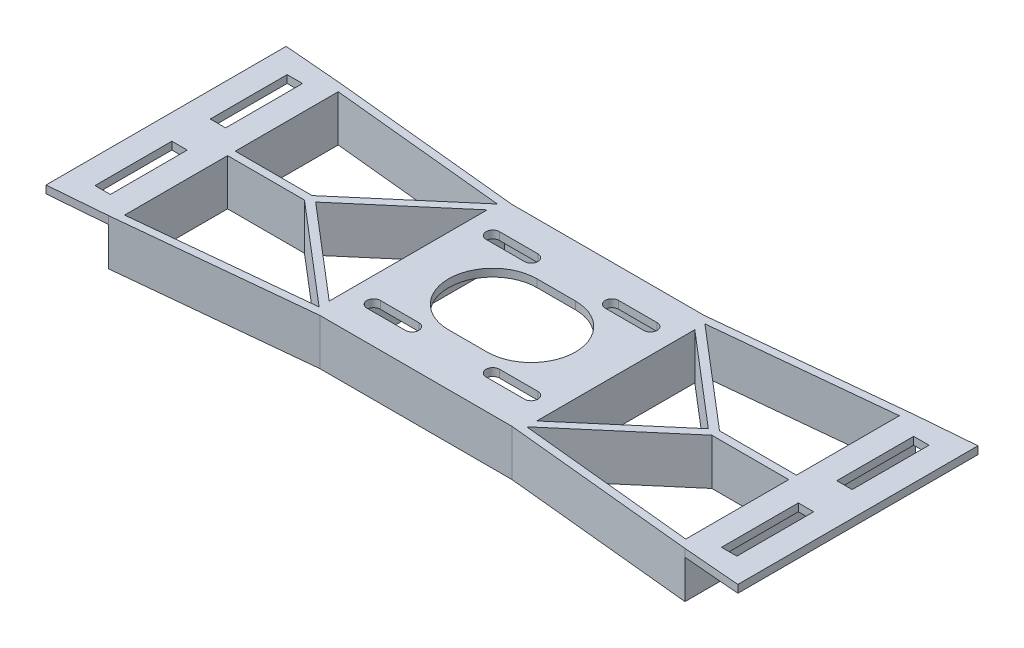
from build123d import *

# Parameters (mm, degrees)
SKETCH1_W           = 170
SKETCH1_H           = 50
BOSS_EXTRUDE1_DEPTH = 2
SKETCH2_W           = 2
SKETCH2_H           = 50
BOSS_EXTRUDE2_DEPTH = 10
SKETCH3_W           = 150
SKETCH3_H           = 2
BOSS_EXTRUDE3_DEPTH = 10
SKETCH4_W           = 60
SKETCH4_H           = 50
CUT_EXTRUDE2_DEPTH  = 13
BOSS_EXTRUDE5_DEPTH = 12
BOSS_EXTRUDE7_DEPTH = 2
SKETCH8_W           = 4
SKETCH8_H           = 20
CUT_EXTRUDE3_DEPTH  = 2


with BuildPart() as part:
    # Sketch1 → Boss-Extrude1 (new body)
    with BuildSketch(Plane(origin=(0, 0, 0), x_dir=(1, 0, 0), z_dir=(0, 1, 0))):
        with Locations((15.5, 15.5)):
            Rectangle(SKETCH1_W, SKETCH1_H)
        with BuildLine():
            Line((5, 32.75), (-5, 32.75))
            ThreePointArc((-5, 32.75), (-6.75, 31), (-5, 29.25))
            Line((-5, 29.25), (5, 29.25))
            ThreePointArc((5, 29.25), (6.749999891, 31), (5, 32.75))
        make_face(mode=Mode.SUBTRACT)
        with BuildLine():
            Line((26, 29.25), (36, 29.25))
            ThreePointArc((36, 29.25), (37.75, 31), (36, 32.75))
            Line((36, 32.75), (26, 32.75))
            ThreePointArc((26, 32.75), (24.25, 31), (26, 29.25))
        make_face(mode=Mode.SUBTRACT)
        with BuildLine():
            Line((-5, 1.75), (5, 1.75))
            ThreePointArc((5, 1.75), (6.75, 0), (5, -1.75))
            Line((5, -1.75), (-5, -1.75))
            ThreePointArc((-5, -1.75), (-6.75, 0), (-5, 1.75))
        make_face(mode=Mode.SUBTRACT)
        with BuildLine():
            Line((26, -1.75), (36, -1.75))
            ThreePointArc((36, -1.75), (37.75, 0), (36, 1.75))
            Line((36, 1.75), (26, 1.75))
            ThreePointArc((26, 1.75), (24.25, 0), (26, -1.75))
        make_face(mode=Mode.SUBTRACT)
        with BuildLine():
            Line((10.5, 27), (20.5, 27))
            ThreePointArc((20.5, 27), (32, 15.5), (20.5, 4))
            Line((20.5, 4), (10.5, 4))
            ThreePointArc((10.5, 4), (-1, 15.5), (10.5, 27))
        make_face(mode=Mode.SUBTRACT)
    extrude(amount=BOSS_EXTRUDE1_DEPTH)

    # Sketch2 → Boss-Extrude2 (add)
    with BuildSketch(Plane(origin=(0, 0, 0), x_dir=(-1, 0, 0), z_dir=(0, -1, 0))):
        with Locations((60.5, 15.5)):
            Rectangle(SKETCH2_W, SKETCH2_H)
        with Locations((-91.5, 15.5)):
            Rectangle(SKETCH2_W, SKETCH2_H)
    extrude(amount=BOSS_EXTRUDE2_DEPTH)

    # Sketch3 → Boss-Extrude3 (add)
    with BuildSketch(Plane(origin=(0, 0, 0), x_dir=(-1, 0, 0), z_dir=(0, -1, 0))):
        with Locations((-15.5, 39.5)):
            Rectangle(SKETCH3_W, SKETCH3_H)
        with Locations((-15.5, -8.5)):
            Rectangle(SKETCH3_W, SKETCH3_H)
    extrude(amount=BOSS_EXTRUDE3_DEPTH)

    # Sketch4 → Cut-Extrude2 (cut, through all)
    with BuildSketch(Plane(origin=(0, 2, 0), x_dir=(1, 0, 0), z_dir=(0, 1, 0))):
        with Locations((-39.5, 15.5)):
            Rectangle(SKETCH4_W, SKETCH4_H)
    cut_extrude2 = extrude(amount=-CUT_EXTRUDE2_DEPTH, mode=Mode.SUBTRACT)

    # Mirror1: Cut-Extrude2 across plane
    add(cut_extrude2.mirror(Plane.ZY.offset(-15.5)), mode=Mode.SUBTRACT)

    # Sketch5 → Boss-Extrude5 (add)
    with BuildSketch(Plane(origin=(0, 2, 0), x_dir=(1, 0, 0), z_dir=(0, 1, 0))):
        Polygon((40.5, 40.5), (90.5, 45.5), (90.5, -14.5), (40.5, -9.5), (40.5, -7.690024876), (40.5, 38.5), align=None)
        Polygon((42.5, 38.690024876), (68.491666638, 16.5), (88.5, 16.5), (88.5, 18.080254606), (88.5, 43.290024876), align=None, mode=Mode.SUBTRACT)
        Polygon((88.5, 14.5), (68.491666638, 14.5), (42.5, -7.690024876), (88.5, -12.290024876), align=None, mode=Mode.SUBTRACT)
        Polygon((66.582731952, 15.5), (42.5, 36.060298366), (42.5, -5.060298366), align=None, mode=Mode.SUBTRACT)
    boss_extrude5 = extrude(amount=-BOSS_EXTRUDE5_DEPTH)

    # Sketch7 → Boss-Extrude7 (add)
    with BuildSketch(Plane(origin=(0, 2, 0), x_dir=(1, 0, 0), z_dir=(0, 1, 0))):
        Polygon((90.5, -14.5), (105.5, -15.740832862), (105.5, 46.740832862), (90.5, 45.5), align=None)
    boss_extrude7 = extrude(amount=-BOSS_EXTRUDE7_DEPTH)

    # Sketch8 → Cut-Extrude3 (cut)
    with BuildSketch(Plane(origin=(0, 2, 0), x_dir=(1, 0, 0), z_dir=(0, 1, 0))):
        with Locations((97, 0.5)):
            Rectangle(SKETCH8_W, SKETCH8_H)
        with Locations((97, 30.5)):
            Rectangle(SKETCH8_W, SKETCH8_H)
    cut_extrude3 = extrude(amount=-CUT_EXTRUDE3_DEPTH, mode=Mode.SUBTRACT)

    # Mirror2: Boss-Extrude5, Boss-Extrude7, Cut-Extrude3 across plane
    add(boss_extrude5.mirror(Plane.ZY.offset(-15.5)))
    add(boss_extrude7.mirror(Plane.ZY.offset(-15.5)))
    add(cut_extrude3.mirror(Plane.ZY.offset(-15.5)), mode=Mode.SUBTRACT)


solid = part.part
